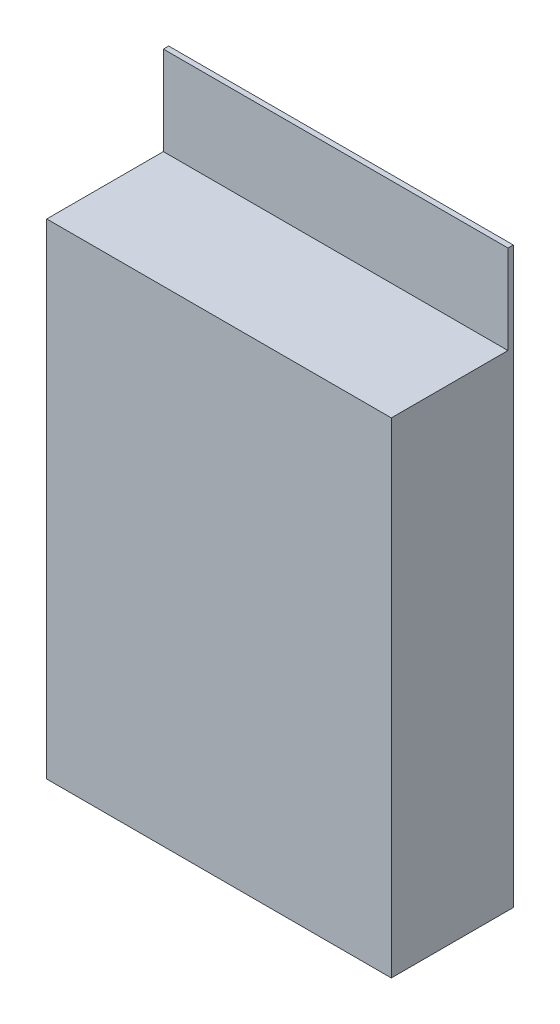
from build123d import *

# Parameters (mm, degrees)
SKETCH1_W           = 66.04
SKETCH1_H           = 92.964
BOSS_EXTRUDE1_DEPTH = 23.368
SKETCH3_W           = 66.04
SKETCH3_H           = 1.016
BOSS_EXTRUDE2_DEPTH = 17.018


with BuildPart() as part:
    # Sketch1 → Boss-Extrude1 (new body)
    with BuildSketch(Plane.XY):
        Rectangle(SKETCH1_W, SKETCH1_H)
    extrude(amount=BOSS_EXTRUDE1_DEPTH)

    # Sketch3 → Boss-Extrude2 (add)
    with BuildSketch(Plane(origin=(0, 46.482, 0), x_dir=(1, 0, 0), z_dir=(0, 1, 0))):
        with Locations((0, -0.508)):
            Rectangle(SKETCH3_W, SKETCH3_H)
    extrude(amount=BOSS_EXTRUDE2_DEPTH)


solid = part.part
